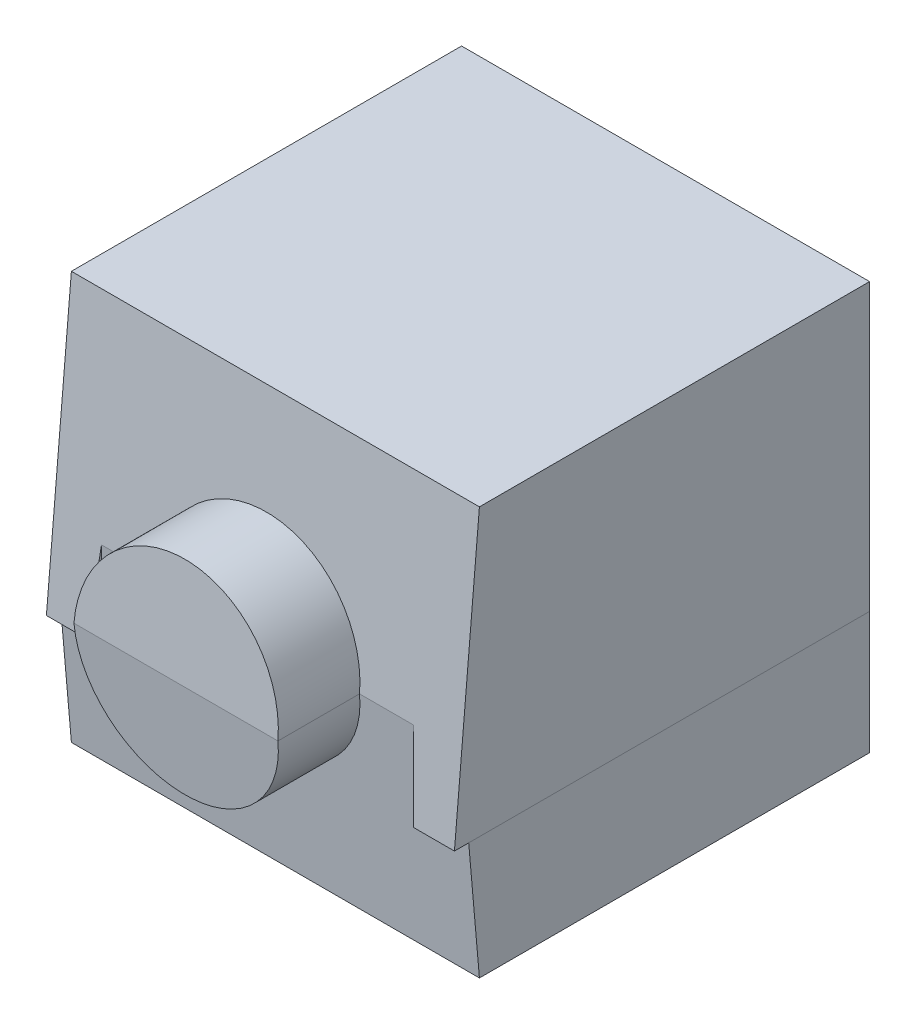
from build123d import *

# Parameters (mm, degrees)
SKIZZE1_W                       = 10
SKIZZE1_H                       = 10
AUFSATZ_LINEAR_AUSTRAGEN1_DEPTH = 5
SKIZZE2_R                       = 2.5
AUFSATZ_LINEAR_AUSTRAGEN2_DEPTH = 2
ABSPALTEN1_SURFACE_1_BACK       = 19.547
ABSPALTEN1_SURFACE_1_DEPTH      = 39.094
ABSPALTEN1_SURFACE_2_BACK       = 19.547
ABSPALTEN1_SURFACE_2_DEPTH      = 39.094
FORMSCHR_GE5_ANGLE              = -5
FORMSCHR_GE6_ANGLE              = -5


with BuildPart() as part:
    # Skizze1 → Aufsatz-Linear austragen1 (new, symmetric)
    with BuildSketch(Plane(origin=(0, 0, 0), x_dir=(1, 0, 0), z_dir=(0, 1, 0))):
        Rectangle(SKIZZE1_W, SKIZZE1_H)
    extrude(amount=AUFSATZ_LINEAR_AUSTRAGEN1_DEPTH, both=True)

    # Skizze2 → Aufsatz-Linear austragen2 (add)
    with BuildSketch(Plane.XY.offset(5)):
        with Locations(Location((0, 0, 0), (0, 0, 180))):
            Circle(SKIZZE2_R)
    extrude(amount=AUFSATZ_LINEAR_AUSTRAGEN2_DEPTH)


with BuildPart() as body_2:
    # Abspalten1: the piece behind the surface
    add(part.part)
    # Abspalten1 surface: a surface, the sketch's curves swept straight by 39.094 mm
    with BuildLine(Plane.XY.offset(5).offset(-ABSPALTEN1_SURFACE_1_BACK), mode=Mode.PRIVATE) as abspalten1_surface_1_path:
        Line((-5, -2), (-4, -2))
        Line((-4, -2), (-3.825022673, 0))
        Line((-3.825022673, 0), (3.825022673, 0))
        Line((3.825022673, 0), (4, -2))
        Line((4, -2), (5, -2))
    abspalten1_surface_1 = Shell.extrude(abspalten1_surface_1_path.wire(), (0 * ABSPALTEN1_SURFACE_1_DEPTH, 0 * ABSPALTEN1_SURFACE_1_DEPTH, 1 * ABSPALTEN1_SURFACE_1_DEPTH))
    split(bisect_by=abspalten1_surface_1, keep=Keep.BOTTOM)

    # Formschräge6
    formschr_ge6_faces = [body_2.faces().sort_by_distance(p)[0] for p in [
        (0, -3.079601476, 5),
        (0, -1.061032954, 7),
    ]]
    draft(formschr_ge6_faces, Plane(origin=(-3.825022673, 0, -5.01), x_dir=(1, 0, 0), z_dir=(0, 1, 0)), FORMSCHR_GE6_ANGLE)


with BuildPart() as part_1:
    add(part.part)

    # Abspalten1: split by a surface, the side it looks to stays
    # Abspalten1 surface: a surface, the sketch's curves swept straight by 39.094 mm
    with BuildLine(Plane.XY.offset(5).offset(-ABSPALTEN1_SURFACE_2_BACK), mode=Mode.PRIVATE) as abspalten1_surface_2_path:
        Line((-5, -2), (-4, -2))
        Line((-4, -2), (-3.825022673, 0))
        Line((-3.825022673, 0), (3.825022673, 0))
        Line((3.825022673, 0), (4, -2))
        Line((4, -2), (5, -2))
    abspalten1_surface_2 = Shell.extrude(abspalten1_surface_2_path.wire(), (0 * ABSPALTEN1_SURFACE_2_DEPTH, 0 * ABSPALTEN1_SURFACE_2_DEPTH, 1 * ABSPALTEN1_SURFACE_2_DEPTH))
    split(bisect_by=abspalten1_surface_2, keep=Keep.TOP)

    # Formschräge5
    formschr_ge5_faces = [part_1.faces().sort_by_distance(p)[0] for p in [
        (0, 1.061032954, 7),
        (4.877934444, 1.5, 5),
    ]]
    draft(formschr_ge5_faces, Plane(origin=(-3.825022673, 0, -5.01), x_dir=(-1, 0, 0), z_dir=(0, -1, 0)), FORMSCHR_GE5_ANGLE)


solid = Compound([body_2.part, part_1.part])
